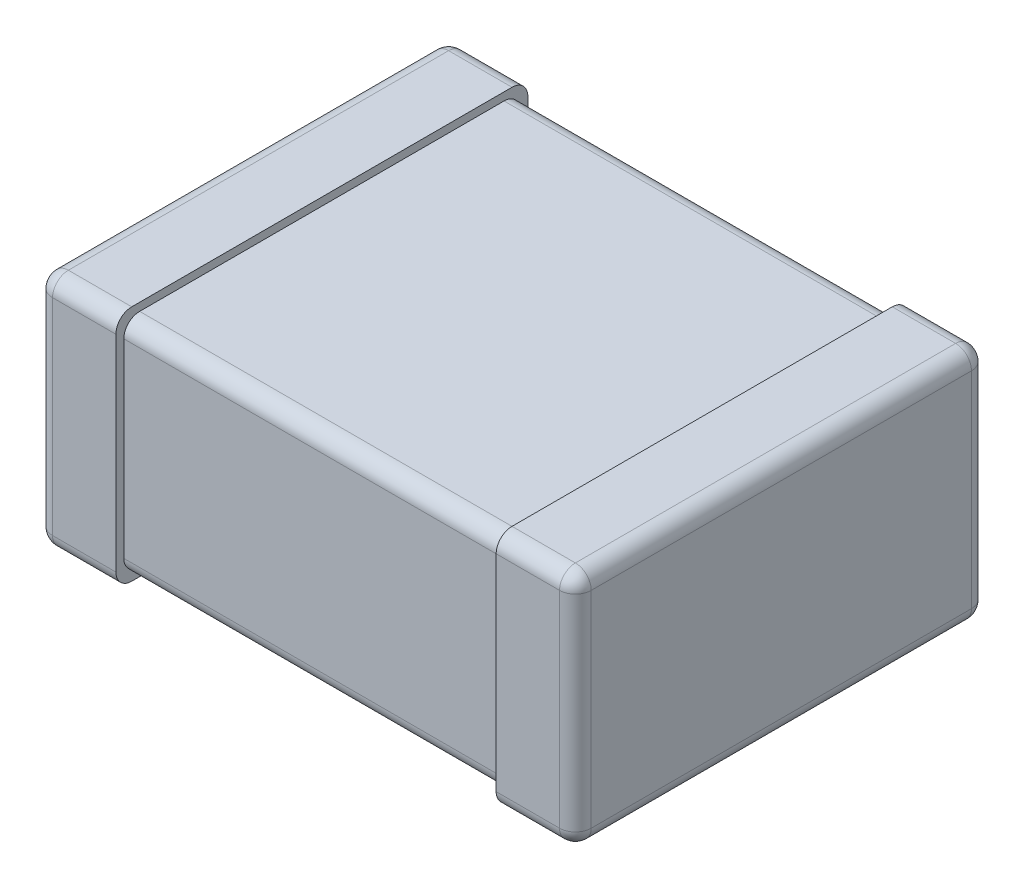
from build123d import *

# Parameters (mm, degrees)
SKETCH1_W             = 0.5
SKETCH1_H             = 2.6
BOSS_EXTRUDE1_DEPTH   = 1.5
BOSS_EXTRUDE1_2_DEPTH = 1.5
BOSS_EXTRUDE2_START   = 0.05
SKETCH2_W             = 2.4
SKETCH2_H             = 2.5
BOSS_EXTRUDE2_DEPTH   = 1.4
FILLET1_R             = 0.1


with BuildPart() as part:
    # Sketch1 → Boss-Extrude1 (new body)
    with BuildSketch(Plane(origin=(0, 0, 0), x_dir=(1, 0, 0), z_dir=(0, 1, 0))):
        with Locations((0.25, 0)):
            Rectangle(SKETCH1_W, SKETCH1_H)
    extrude(amount=BOSS_EXTRUDE1_DEPTH)



with BuildPart() as body_2:
    # Sketch1 → Boss-Extrude1 2 (new body)
    with BuildSketch(Plane(origin=(0, 0, 0), x_dir=(1, 0, 0), z_dir=(0, 1, 0))):
        with Locations((3.15, 0)):
            Rectangle(SKETCH1_W, SKETCH1_H)
    extrude(amount=BOSS_EXTRUDE1_2_DEPTH)


with BuildPart() as part_1:
    add(part.part)

    add(body_2.part)  # Boss-Extrude2 merges body 2
    # Sketch2 → Boss-Extrude2 (add)
    with BuildSketch(Plane(origin=(0, 0, 0), x_dir=(1, 0, 0), z_dir=(0, 1, 0)).offset(BOSS_EXTRUDE2_START)):
        with Locations((1.7, 0)):
            Rectangle(SKETCH2_W, SKETCH2_H)
    extrude(amount=BOSS_EXTRUDE2_DEPTH)

    # Fillet1
    fillet1_edges = [part_1.edges().sort_by_distance(p)[0] for p in [
        (0.25, 1.5, 1.3),
        (1.7, 0.05, -1.25),
        (1.7, 0.05, 1.25),
        (1.7, 1.45, -1.25),
        (1.7, 1.45, 1.25),
        (3.15, 0, -1.3),
        (3.4, 0.75, -1.3),
        (3.15, 0, 1.3),
        (3.4, 0, 0),
        (3.4, 0.75, 1.3),
        (3.15, 1.5, -1.3),
        (3.15, 1.5, 1.3),
        (3.4, 1.5, 0),
        (0.25, 1.5, -1.3),
        (0.25, 0, 1.3),
        (0, 0, 0),
        (0.25, 0, -1.3),
        (0, 1.5, 0),
        (0, 0.75, 1.3),
        (0, 0.75, -1.3),
    ]]
    fillet(fillet1_edges, radius=FILLET1_R)


solid = part_1.part
